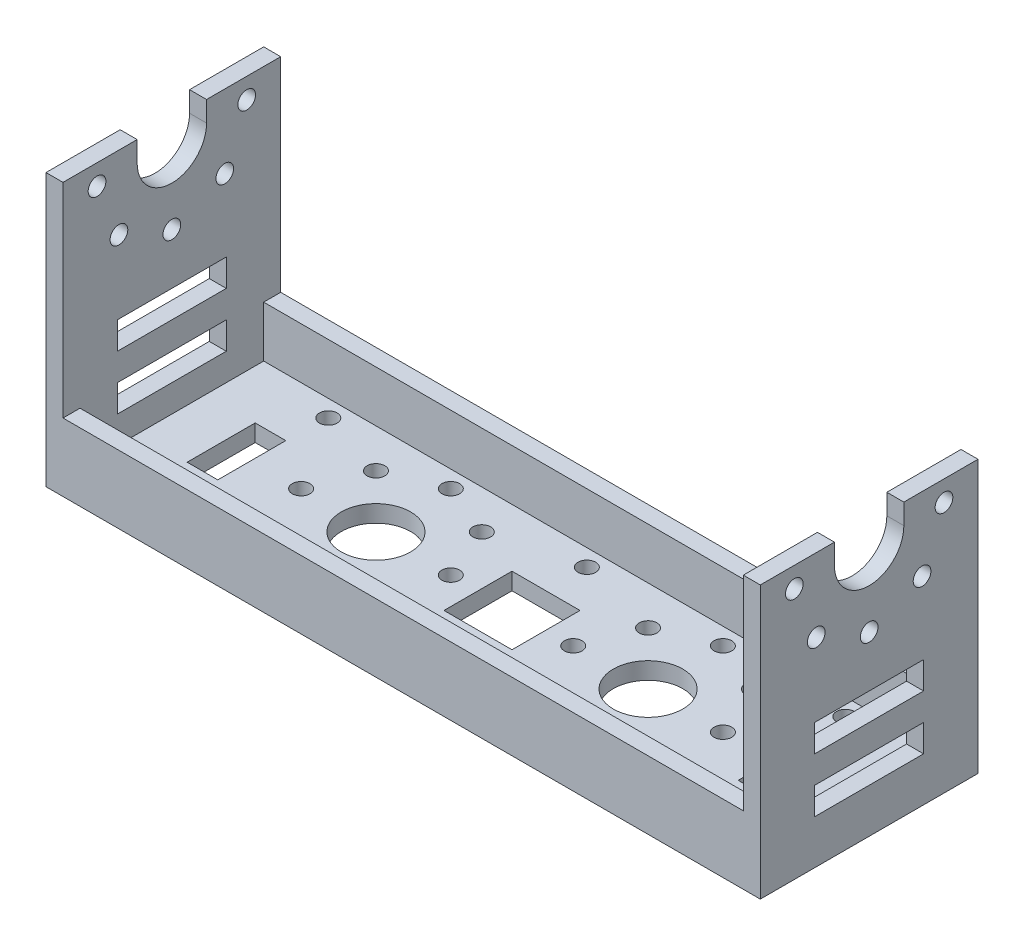
from build123d import *

# Parameters (mm, degrees)
SKETCH2_W              = 105
SKETCH2_H              = 32
BOSS_EXTRUDE1_DEPTH    = 40
SKETCH3_W              = 100
SKETCH3_H              = 32
CUT_EXTRUDE1_DEPTH     = 30
SKETCH4_W              = 100
SKETCH4_H              = 27
CUT_EXTRUDE2_DEPTH     = 7.5
F_10_0MM_DOWEL_HOLE1_D = 10.2
F_2_5MM_DOWEL_HOLE1_D  = 2.6
CIRPATTERN1_COUNT      = 8
F_2_5MM_DOWEL_HOLE2_D  = 2.6
LPATTERN1_COUNT        = 3
LPATTERN1_PITCH        = 38
MIRROR1_COPY_1_D       = 2.6
MIRROR1_COPY_2_D       = 2.6
MIRROR1_COPY_3_D       = 2.6
MIRROR1_COPY_4_D       = 2.6
MIRROR1_COPY_5_D       = 2.6
MIRROR1_COPY_6_D       = 2.6
MIRROR1_COPY_7_D       = 2.6
MIRROR1_COPY_8_D       = 2.6
CUT_EXTRUDE3_DEPTH     = 72.75
F_2_5MM_DOWEL_HOLE3_D  = 2.6
CIRPATTERN3_COUNT      = 5
CIRPATTERN3_ANGLE      = 180
SKETCH18_W             = 16
SKETCH18_H             = 4
CUT_EXTRUDE4_DEPTH     = 72.75
SKETCH19_W             = 10
SKETCH19_H             = 10
SKETCH19_W_2           = 4.5
CUT_EXTRUDE5_DEPTH     = 145.5


with BuildPart() as part:
    # Sketch2 → Boss-Extrude1 (new body)
    with BuildSketch(Plane(origin=(0, 0, 0), x_dir=(1, 0, 0), z_dir=(0, 1, 0))):
        Rectangle(SKETCH2_W, SKETCH2_H)
    extrude(amount=BOSS_EXTRUDE1_DEPTH)

    # Sketch3 → Cut-Extrude1 (cut)
    with BuildSketch(Plane(origin=(0, 40, 0), x_dir=(1, 0, 0), z_dir=(0, 1, 0))):
        Rectangle(SKETCH3_W, SKETCH3_H)
    extrude(amount=-CUT_EXTRUDE1_DEPTH, mode=Mode.SUBTRACT)

    # Sketch4 → Cut-Extrude2 (cut)
    with BuildSketch(Plane(origin=(0, 10, 0), x_dir=(1, 0, 0), z_dir=(0, 1, 0))):
        Rectangle(SKETCH4_W, SKETCH4_H)
    extrude(amount=-CUT_EXTRUDE2_DEPTH, mode=Mode.SUBTRACT)

    # Ø10.0mm Dowel Hole1 (through all)
    with Locations(Plane(origin=(0, 0, 0), x_dir=(-1, 0, 0), z_dir=(0, -1, 0))):
        with Locations((-20, 0), (20, 0)):
            Hole(F_10_0MM_DOWEL_HOLE1_D / 2)

    # Ø2.5mm Dowel Hole1 (through all)
    with Locations(Plane(origin=(0, 0, 0), x_dir=(-1, 0, 0), z_dir=(0, -1, 0))):
        with Locations((-20, 11)):
            f_2_5mm_dowel_hole1 = Hole(F_2_5MM_DOWEL_HOLE1_D / 2)

    # CirPattern1: Ø2.5mm Dowel Hole1 ×8 about axis
    cirpattern1_axis = Axis((20, 0, 0), (0, -1, 0))
    for i in range(1, CIRPATTERN1_COUNT):
        add(f_2_5mm_dowel_hole1.rotate(cirpattern1_axis, i * 360 / CIRPATTERN1_COUNT), mode=Mode.SUBTRACT)

    # Ø2.5mm Dowel Hole2 (through all)
    with Locations(Plane(origin=(0, 0, 0), x_dir=(-1, 0, 0), z_dir=(0, -1, 0))):
        with Locations((-38, 11), (-38, -11)):
            f_2_5mm_dowel_hole2 = Hole(F_2_5MM_DOWEL_HOLE2_D / 2)

    # LPattern1: Ø2.5mm Dowel Hole2 ×3
    with Locations(*[(-i * LPATTERN1_PITCH, 0, 0) for i in range(1, LPATTERN1_COUNT)]):
        add(f_2_5mm_dowel_hole2, mode=Mode.SUBTRACT)

    # Mirror1 copy 1 (through all)
    with Locations(Plane(origin=(-5.857864376, 0, -14.142135624), x_dir=(0.7071067811865476, 0, -0.7071067811865475), z_dir=(0, -1, 0))):
        with Locations((-20, -11)):
            Hole(MIRROR1_COPY_1_D / 2)

    # Mirror1 copy 2 (through all)
    with Locations(Plane(origin=(-20, 0, -20), x_dir=(0, 0, -1), z_dir=(0, -1, 0))):
        with Locations((-20, -11)):
            Hole(MIRROR1_COPY_2_D / 2)

    # Mirror1 copy 3 (through all)
    with Locations(Plane(origin=(-34.142135624, 0, -14.142135624), x_dir=(-0.7071067811865475, 0, -0.7071067811865476), z_dir=(0, -1, 0))):
        with Locations((-20, -11)):
            Hole(MIRROR1_COPY_3_D / 2)

    # Mirror1 copy 4 (through all)
    with Locations(Plane(origin=(-40, 0, 0), x_dir=(-1, 0, 0), z_dir=(0, -1, 0))):
        with Locations((-20, -11)):
            Hole(MIRROR1_COPY_4_D / 2)

    # Mirror1 copy 5 (through all)
    with Locations(Plane(origin=(-34.142135624, 0, 14.142135624), x_dir=(-0.7071067811865477, 0, 0.7071067811865475), z_dir=(0, -1, 0))):
        with Locations((-20, -11)):
            Hole(MIRROR1_COPY_5_D / 2)

    # Mirror1 copy 6 (through all)
    with Locations(Plane(origin=(-20, 0, 20), x_dir=(0, 0, 1), z_dir=(0, -1, 0))):
        with Locations((-20, -11)):
            Hole(MIRROR1_COPY_6_D / 2)

    # Mirror1 copy 7 (through all)
    with Locations(Plane(origin=(-5.857864376, 0, 14.142135624), x_dir=(0.7071067811865474, 0, 0.7071067811865477), z_dir=(0, -1, 0))):
        with Locations((-20, -11)):
            Hole(MIRROR1_COPY_7_D / 2)

    # Mirror1 copy 8 (through all)
    with Locations(Plane.XZ):
        with Locations((-20, -11)):
            Hole(MIRROR1_COPY_8_D / 2)

    # Sketch14 → Cut-Extrude3 (cut, symmetric)
    with BuildSketch(Plane(origin=(0, 0, 0), x_dir=(0, 0, -1), z_dir=(1, 0, 0))):
        with BuildLine():
            Line((-5.1, 40), (5.1, 40))
            Line((5.1, 40), (5.1, 37))
            ThreePointArc((5.1, 37), (0, 31.9), (-5.1, 37))
            Line((-5.1, 37), (-5.1, 40))
        make_face()
    extrude(amount=CUT_EXTRUDE3_DEPTH, both=True, mode=Mode.SUBTRACT)

    # Ø2.5mm Dowel Hole3 (through all)
    with Locations(Plane(origin=(52.5, 0, 0), x_dir=(0, 0, -1), z_dir=(1, 0, 0))):
        with Locations((11, 37)):
            f_2_5mm_dowel_hole3 = Hole(F_2_5MM_DOWEL_HOLE3_D / 2)

    # CirPattern3: Ø2.5mm Dowel Hole3 ×5 about axis
    cirpattern3_axis = Axis((-72.75, 37, 0), (-1, 0, 0))
    for i in range(1, CIRPATTERN3_COUNT):
        add(f_2_5mm_dowel_hole3.rotate(cirpattern3_axis, i * CIRPATTERN3_ANGLE / (CIRPATTERN3_COUNT - 1)), mode=Mode.SUBTRACT)

    # Sketch18 → Cut-Extrude4 (cut, symmetric)
    with BuildSketch(Plane(origin=(0, 0, 0), x_dir=(0, 0, -1), z_dir=(1, 0, 0))):
        with Locations((0, 16.5)):
            Rectangle(SKETCH18_W, SKETCH18_H)
        with Locations((0, 8.5)):
            Rectangle(SKETCH18_W, SKETCH18_H)
    extrude(amount=CUT_EXTRUDE4_DEPTH, both=True, mode=Mode.SUBTRACT)

    # Sketch19 → Cut-Extrude5 (cut)
    with BuildSketch(Plane.XZ):
        Rectangle(SKETCH19_W, SKETCH19_H)
        with Locations((40.5, 0)):
            Rectangle(SKETCH19_W_2, SKETCH19_H)
        with Locations((-40.5, 0)):
            Rectangle(SKETCH19_W_2, SKETCH19_H)
    extrude(amount=-CUT_EXTRUDE5_DEPTH, mode=Mode.SUBTRACT)


solid = part.part
